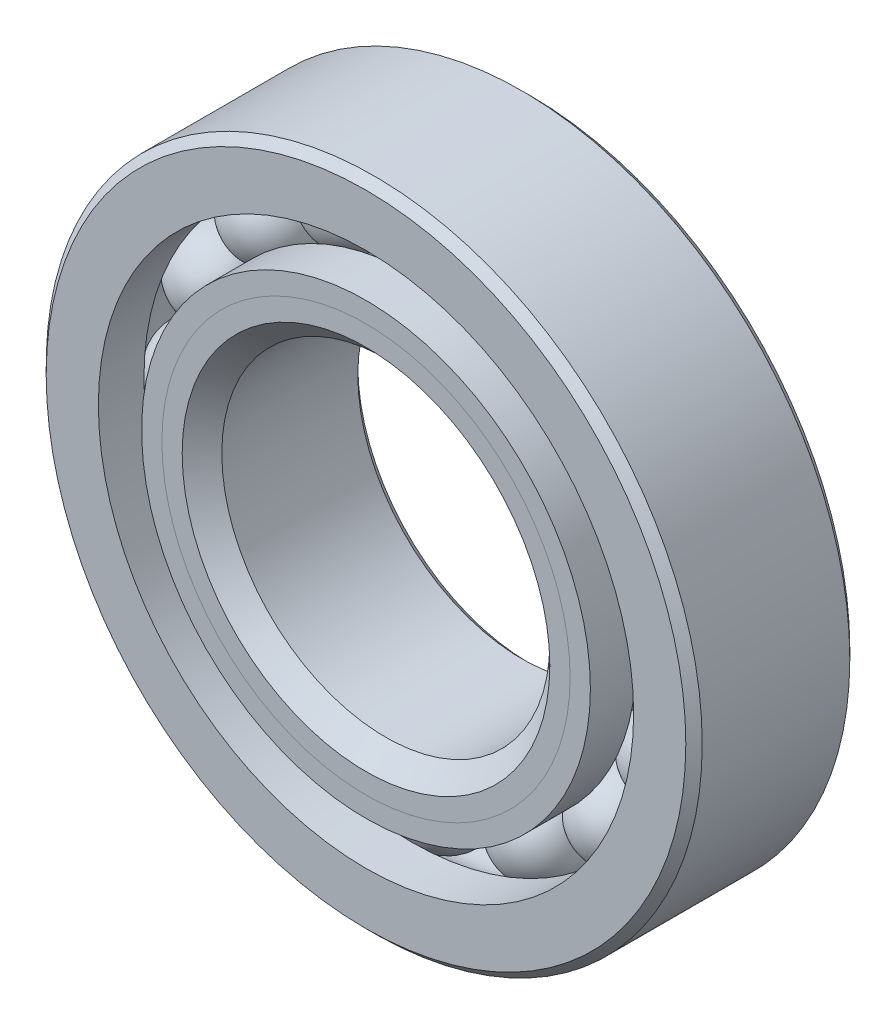
from build123d import *

# Parameters (mm, degrees)
CIRPATTERN1_COUNT = 16


with BuildPart() as part:
    # Sketch1 → Revolve1 (revolve)
    with BuildSketch(Plane(origin=(0, 0, 0), x_dir=(0, 0, -1), z_dir=(1, 0, 0))):
        with BuildLine():
            Line((1.42875, 6.35), (-1.42875, 6.35))
            Line((-1.42875, 6.35), (-1.5875, 6.19125))
            Line((-1.5875, 6.19125), (-1.5875, 5.181181319))
            Line((-1.5875, 5.181181319), (-0.705555556, 5.181181319))
            ThreePointArc((-0.705555556, 5.181181319), (0, 5.582928357), (0.705555556, 5.181181319))
            Line((0.705555556, 5.181181319), (1.5875, 5.181181319))
            Line((1.5875, 5.181181319), (1.5875, 6.19125))
            Line((1.5875, 6.19125), (1.42875, 6.35))
        make_face()
    revolve(axis=Axis((0, 0, 1.5875), (0, 0, -1)))


with BuildPart() as body_2:
    # Sketch2 → Revolve2 (revolve)
    with BuildSketch(Plane(origin=(0, 0, 0), x_dir=(0, 0, -1), z_dir=(1, 0, 0))):
        with BuildLine():
            Line((-1.5875, 4.343818681), (-0.705555556, 4.343818681))
            ThreePointArc((-0.705555556, 4.343818681), (-0.405958534, 4.049548138), (0, 3.942071643))
            Line((0, 3.942071643), (0, 3.558535822))
            Line((0, 3.558535822), (-1.19485857, 3.558535822))
            Line((-1.19485857, 3.558535822), (-1.5875, 3.951177251))
            Line((-1.5875, 3.951177251), (-1.5875, 4.343818681))
        make_face()
    revolve(axis=Axis((0, 0, 1.5875), (0, 0, -1)))


with BuildPart() as body_3:
    # Sketch3 → Revolve3 (revolve)
    with BuildSketch(Plane(origin=(0, 0, 0), x_dir=(0, 0, -1), z_dir=(1, 0, 0))):
        with BuildLine():
            Line((-1.5875, 3.951177251), (-1.19485857, 3.558535822))
            Line((-1.19485857, 3.558535822), (0, 3.558535822))
            Line((0, 3.558535822), (0, 3.942071643))
            ThreePointArc((0, 3.942071643), (0.405958534, 4.049548138), (0.705555556, 4.343818681))
            Line((0.705555556, 4.343818681), (1.5875, 4.343818681))
            Line((1.5875, 4.343818681), (1.5875, 3.33375))
            Line((1.5875, 3.33375), (1.42875, 3.175))
            Line((1.42875, 3.175), (-1.203964178, 3.175))
            Line((-1.203964178, 3.175), (-1.5875, 3.558535822))
            Line((-1.5875, 3.558535822), (-1.5875, 3.951177251))
        make_face()
    revolve(axis=Axis((0, 0, 1.5875), (0, 0, -1)))


with BuildPart() as body_4:
    # Sketch4 → Revolve4 (revolve)
    with BuildSketch(Plane(origin=(0, 0, 0), x_dir=(0, 0, -1), z_dir=(1, 0, 0))):
        with BuildLine():
            Line((-0.820428357, 4.7625), (0.820428357, 4.7625))
            ThreePointArc((0.820428357, 4.7625), (0, 5.582928357), (-0.820428357, 4.7625))
        make_face()
    revolve(axis=Axis((0, 4.7625, 0.820428357), (0, 0, -1)))


with BuildPart() as cirpattern1_1:
    # CirPattern1: pattern copy
    add(body_4.part.rotate(Axis((0, 0, -1.5875), (0, 0, 1)), 1 * 360 / CIRPATTERN1_COUNT))


with BuildPart() as cirpattern1_2:
    # CirPattern1: pattern copy
    add(body_4.part.rotate(Axis((0, 0, -1.5875), (0, 0, 1)), 2 * 360 / CIRPATTERN1_COUNT))


with BuildPart() as cirpattern1_3:
    # CirPattern1: pattern copy
    add(body_4.part.rotate(Axis((0, 0, -1.5875), (0, 0, 1)), 3 * 360 / CIRPATTERN1_COUNT))


with BuildPart() as cirpattern1_4:
    # CirPattern1: pattern copy
    add(body_4.part.rotate(Axis((0, 0, -1.5875), (0, 0, 1)), 4 * 360 / CIRPATTERN1_COUNT))


with BuildPart() as cirpattern1_5:
    # CirPattern1: pattern copy
    add(body_4.part.rotate(Axis((0, 0, -1.5875), (0, 0, 1)), 5 * 360 / CIRPATTERN1_COUNT))


with BuildPart() as cirpattern1_6:
    # CirPattern1: pattern copy
    add(body_4.part.rotate(Axis((0, 0, -1.5875), (0, 0, 1)), 6 * 360 / CIRPATTERN1_COUNT))


with BuildPart() as cirpattern1_7:
    # CirPattern1: pattern copy
    add(body_4.part.rotate(Axis((0, 0, -1.5875), (0, 0, 1)), 7 * 360 / CIRPATTERN1_COUNT))


with BuildPart() as cirpattern1_8:
    # CirPattern1: pattern copy
    add(body_4.part.rotate(Axis((0, 0, -1.5875), (0, 0, 1)), 8 * 360 / CIRPATTERN1_COUNT))


with BuildPart() as cirpattern1_9:
    # CirPattern1: pattern copy
    add(body_4.part.rotate(Axis((0, 0, -1.5875), (0, 0, 1)), 9 * 360 / CIRPATTERN1_COUNT))


with BuildPart() as cirpattern1_10:
    # CirPattern1: pattern copy
    add(body_4.part.rotate(Axis((0, 0, -1.5875), (0, 0, 1)), 10 * 360 / CIRPATTERN1_COUNT))


with BuildPart() as cirpattern1_11:
    # CirPattern1: pattern copy
    add(body_4.part.rotate(Axis((0, 0, -1.5875), (0, 0, 1)), 11 * 360 / CIRPATTERN1_COUNT))


with BuildPart() as cirpattern1_12:
    # CirPattern1: pattern copy
    add(body_4.part.rotate(Axis((0, 0, -1.5875), (0, 0, 1)), 12 * 360 / CIRPATTERN1_COUNT))


with BuildPart() as cirpattern1_13:
    # CirPattern1: pattern copy
    add(body_4.part.rotate(Axis((0, 0, -1.5875), (0, 0, 1)), 13 * 360 / CIRPATTERN1_COUNT))


with BuildPart() as cirpattern1_14:
    # CirPattern1: pattern copy
    add(body_4.part.rotate(Axis((0, 0, -1.5875), (0, 0, 1)), 14 * 360 / CIRPATTERN1_COUNT))


with BuildPart() as cirpattern1_15:
    # CirPattern1: pattern copy
    add(body_4.part.rotate(Axis((0, 0, -1.5875), (0, 0, 1)), 15 * 360 / CIRPATTERN1_COUNT))


solid = Compound([part.part, body_2.part, body_3.part, body_4.part, cirpattern1_1.part, cirpattern1_2.part, cirpattern1_3.part, cirpattern1_4.part, cirpattern1_5.part, cirpattern1_6.part, cirpattern1_7.part, cirpattern1_8.part, cirpattern1_9.part, cirpattern1_10.part, cirpattern1_11.part, cirpattern1_12.part, cirpattern1_13.part, cirpattern1_14.part, cirpattern1_15.part])
